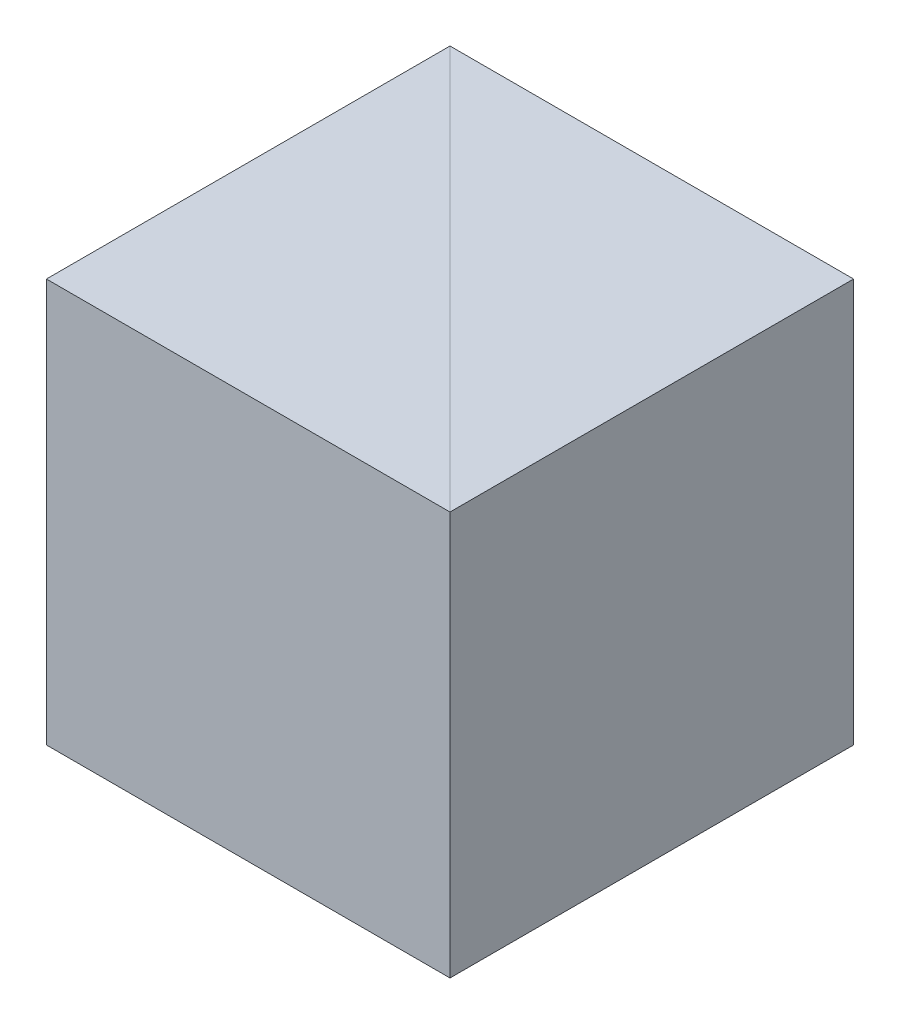
from build123d import *

# Parameters (mm, degrees)
EXTRUDE_1_DEPTH = 50
EXTRUDE_2_DEPTH = 50


with BuildPart() as part:
    # 草图1 → 凸台-拉伸1 (new body)
    with BuildSketch(Plane(origin=(0, 0, 0), x_dir=(1, 0, 0), z_dir=(0, 1, 0))):
        Polygon((0, 0), (0, 50), (-50, 50), align=None)
    extrude(amount=EXTRUDE_1_DEPTH)


with BuildPart() as body_2:
    # 草图2 → 凸台-拉伸2 (new body)
    with BuildSketch(Plane.XZ):
        Polygon((-50, -50), (-50, 0), (0, 0), align=None)
    extrude(amount=-EXTRUDE_2_DEPTH)


solid = Compound([part.part, body_2.part])
